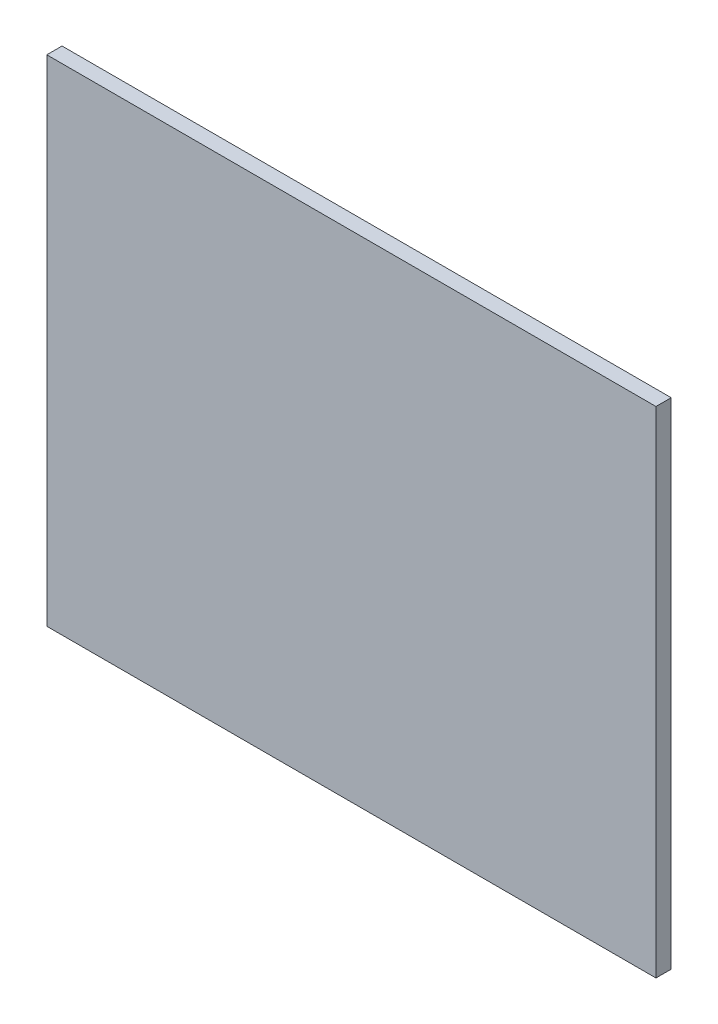
from build123d import *

# Parameters (mm, degrees)
SKETCH_1_W      = 800
SKETCH_1_H      = 650
EXTRUDE_1_DEPTH = 20


with BuildPart() as part:
    # 草图1 → 凸台-拉伸1 (new body)
    with BuildSketch(Plane.XY):
        Rectangle(SKETCH_1_W, SKETCH_1_H)
    extrude(amount=EXTRUDE_1_DEPTH)


solid = part.part
